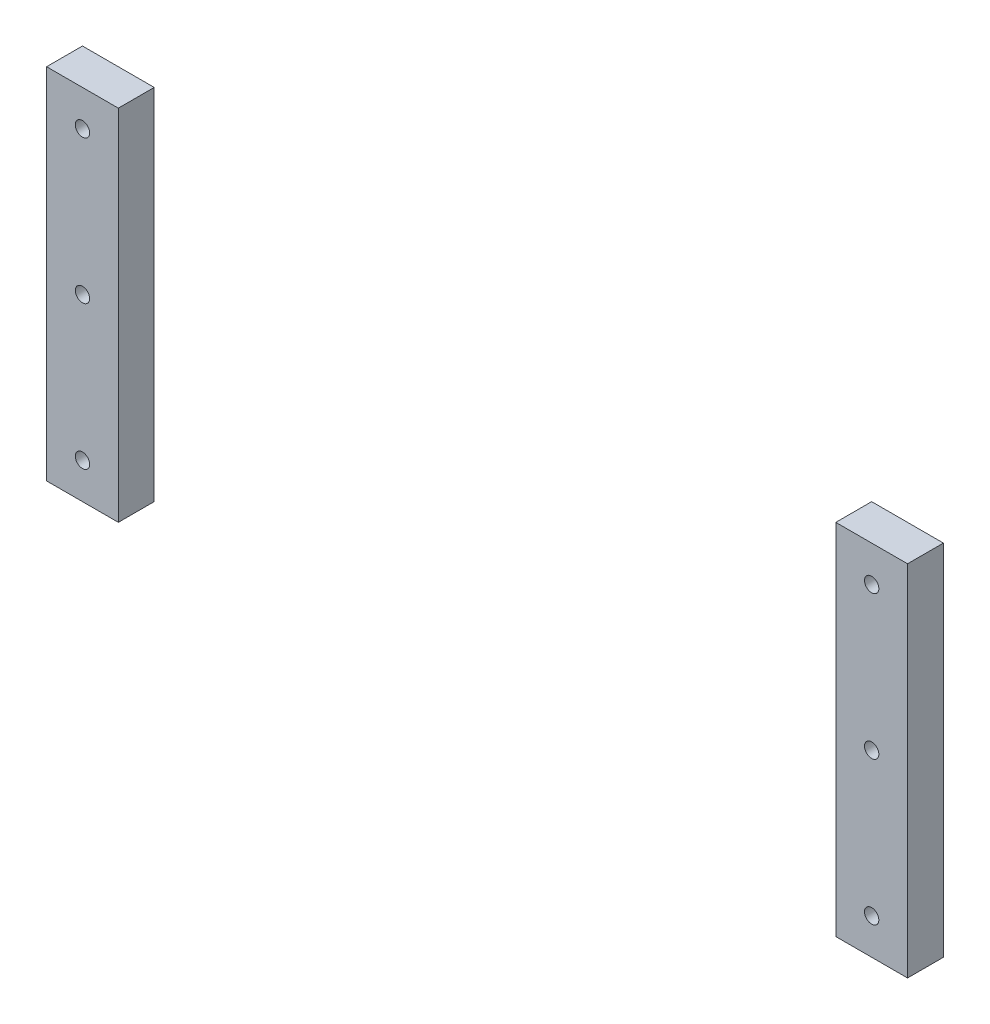
from build123d import *

# Parameters (mm, degrees)
SKETCH1_W              = 20
SKETCH1_H              = 100
SUPPORTEXTRUDE_DEPTH   = 10
SUPPORTEXTRUDE_2_DEPTH = 10
SKETCH2_R              = 2
CUT_EXTRUDE1_DEPTH     = 11


with BuildPart() as part:
    # Sketch1 → SupportExtrude (new body)
    with BuildSketch(Plane.XY):
        with Locations((210, 50)):
            Rectangle(SKETCH1_W, SKETCH1_H)
    extrude(amount=SUPPORTEXTRUDE_DEPTH)


with BuildPart() as body_2:
    # Sketch1 → SupportExtrude 2 (new body)
    with BuildSketch(Plane.XY):
        with Locations((-10, 50)):
            Rectangle(SKETCH1_W, SKETCH1_H)
    extrude(amount=SUPPORTEXTRUDE_2_DEPTH)


with BuildPart() as cut_extrude1_tool:
    # Sketch2 → Cut-Extrude1 (new body, through all)
    with BuildSketch(Plane.XY.offset(10)):
        with Locations((-10, 10)):
            Circle(SKETCH2_R)
        with Locations((-10, 50)):
            Circle(SKETCH2_R)
        with Locations((-10, 90)):
            Circle(SKETCH2_R)
        with Locations((210, 10)):
            Circle(SKETCH2_R)
        with Locations((210, 50)):
            Circle(SKETCH2_R)
        with Locations((210, 90)):
            Circle(SKETCH2_R)
    extrude(amount=-CUT_EXTRUDE1_DEPTH)


with BuildPart() as part_1:
    add(part.part)

    # Cut-Extrude1: cut by cut_extrude1_tool
    add(cut_extrude1_tool.part, mode=Mode.SUBTRACT)


with BuildPart() as body_2_1:
    add(body_2.part)

    # Cut-Extrude1: cut by cut_extrude1_tool
    add(cut_extrude1_tool.part, mode=Mode.SUBTRACT)


solid = Compound([part_1.part, body_2_1.part])
